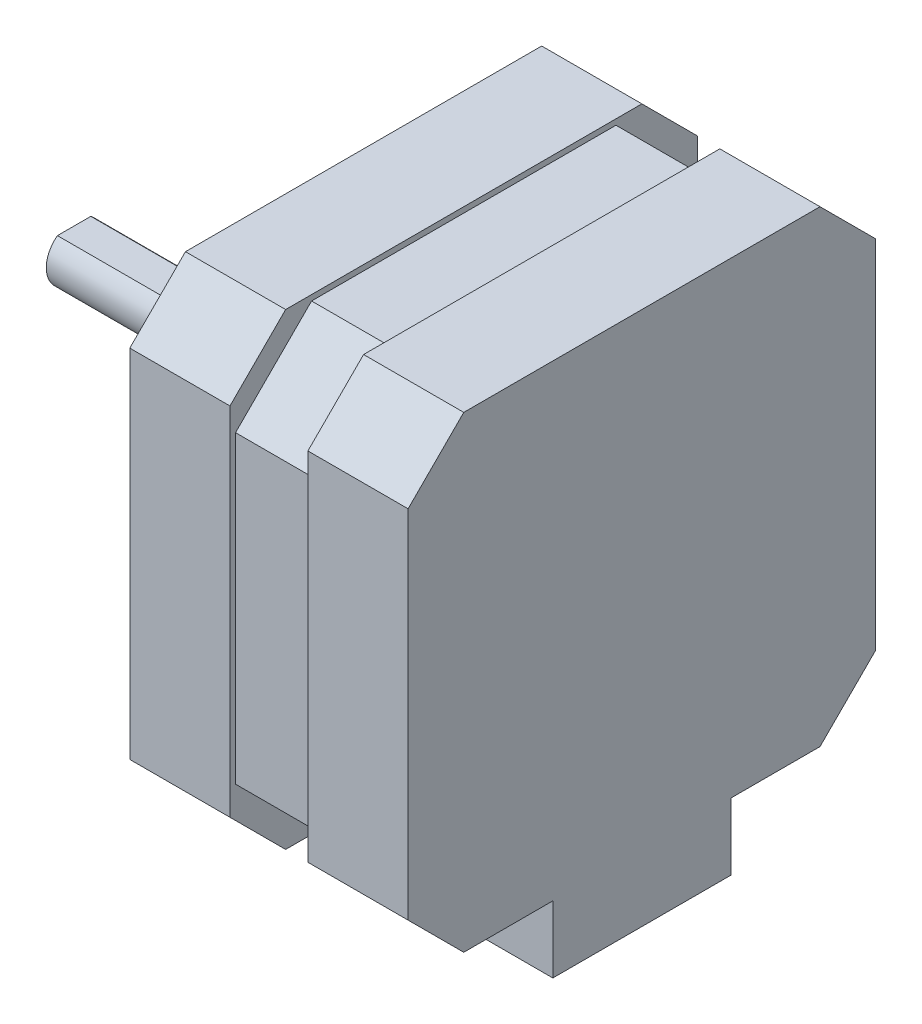
from build123d import *

# Parameters (mm, degrees)
BOSS_EXTRUDE1_DEPTH   = 12.5
CUT_EXTRUDE1_DEPTH    = 3.5
SKETCH4_W             = 7
SKETCH4_H             = 27.34314575
CUT_EXTRUDE2_DEPTH    = 0.5
SKETCH5_W             = 7
SKETCH5_H             = 27.34314575
CUT_EXTRUDE3_DEPTH    = 0.5
SKETCH6_W             = 7
SKETCH6_H             = 27.34314575
CUT_EXTRUDE4_DEPTH    = 0.5
SKETCH7_W             = 7
SKETCH7_H             = 27.34314575
CUT_EXTRUDE5_DEPTH    = 0.5
SKETCH8_R             = 11
BOSS_EXTRUDE2_DEPTH   = 2
SKETCH9_R             = 2.5
BOSS_EXTRUDE3_DEPTH   = 24
M3_TAPPED_HOLE1_D     = 2.5
M3_TAPPED_HOLE1_DEPTH = 6
M3_TAPPED_HOLE1_TIP   = 0.751075774
SKETCH12_W            = 3
SKETCH12_H            = 0.5
CUT_EXTRUDE6_DEPTH    = 20
SKETCH13_W            = 9
SKETCH13_H            = 16
BOSS_EXTRUDE4_DEPTH   = 6


with BuildPart() as part:
    # Sketch1 → Boss-Extrude1 (new body, symmetric)
    with BuildSketch(Plane(origin=(0, 0, 0), x_dir=(0, 0, -1), z_dir=(1, 0, 0))):
        Polygon((-21, 16), (-16, 21), (16, 21), (21, 16), (21, -16), (16, -21), (-16, -21), (-21, -16), align=None)
    extrude(amount=BOSS_EXTRUDE1_DEPTH, both=True)

    # Sketch2 → Cut-Extrude1 (cut, symmetric)
    with BuildSketch(Plane(origin=(0, 0, 0), x_dir=(0, 0, -1), z_dir=(1, 0, 0))):
        Polygon((-21, -13.671572875), (-20.5, -13.671572875), (-13.671572875, -20.5), (-13.671572875, -21), (-16, -21), (-21, -16), align=None)
        Polygon((13.671572875, -21), (13.671572875, -20.5), (20.5, -13.671572875), (21, -13.671572875), (21, -16), (16, -21), align=None)
        Polygon((21, 13.671572875), (20.5, 13.671572875), (13.671572875, 20.5), (13.671572875, 21), (16, 21), (21, 16), align=None)
        Polygon((-13.671572875, 21), (-13.671572875, 20.5), (-20.5, 13.671572875), (-21, 13.671572875), (-21, 16), (-16, 21), align=None)
    extrude(amount=CUT_EXTRUDE1_DEPTH, both=True, mode=Mode.SUBTRACT)

    # Sketch4 → Cut-Extrude2 (cut)
    with BuildSketch(Plane.XY.offset(21)):
        Rectangle(SKETCH4_W, SKETCH4_H)
    extrude(amount=-CUT_EXTRUDE2_DEPTH, mode=Mode.SUBTRACT)

    # Sketch5 → Cut-Extrude3 (cut)
    with BuildSketch(Plane(origin=(0, 21, 0), x_dir=(1, 0, 0), z_dir=(0, 1, 0))):
        Rectangle(SKETCH5_W, SKETCH5_H)
    extrude(amount=-CUT_EXTRUDE3_DEPTH, mode=Mode.SUBTRACT)

    # Sketch6 → Cut-Extrude4 (cut)
    with BuildSketch(Plane(origin=(0, 0, -21), x_dir=(-1, 0, 0), z_dir=(0, 0, -1))):
        Rectangle(SKETCH6_W, SKETCH6_H)
    extrude(amount=-CUT_EXTRUDE4_DEPTH, mode=Mode.SUBTRACT)

    # Sketch7 → Cut-Extrude5 (cut)
    with BuildSketch(Plane.XZ.offset(21)):
        Rectangle(SKETCH7_W, SKETCH7_H)
    extrude(amount=-CUT_EXTRUDE5_DEPTH, mode=Mode.SUBTRACT)

    # Sketch8 → Boss-Extrude2 (add)
    with BuildSketch(Plane.ZY.offset(12.5)):
        Circle(SKETCH8_R)
    extrude(amount=BOSS_EXTRUDE2_DEPTH)

    # Sketch9 → Boss-Extrude3 (add)
    with BuildSketch(Plane.ZY.offset(14.5)):
        Circle(SKETCH9_R)
    extrude(amount=BOSS_EXTRUDE3_DEPTH)

    # M3 Tapped Hole1
    with Locations(Plane.ZY.offset(12.5)):
        with Locations((-15.5, 15.5), (15.5, 15.5), (-15.5, -15.5), (15.5, -15.5)):
            Hole(M3_TAPPED_HOLE1_D / 2, depth=M3_TAPPED_HOLE1_DEPTH)
            with Locations((0, 0, -(M3_TAPPED_HOLE1_DEPTH + M3_TAPPED_HOLE1_TIP / 2))):  # 118° drill point
                Cone(0, M3_TAPPED_HOLE1_D / 2, M3_TAPPED_HOLE1_TIP, mode=Mode.SUBTRACT)

    # Sketch12 → Cut-Extrude6 (cut)
    with BuildSketch(Plane.ZY.offset(38.5)):
        with Locations((0, 2.25)):
            Rectangle(SKETCH12_W, SKETCH12_H)
    extrude(amount=-CUT_EXTRUDE6_DEPTH, mode=Mode.SUBTRACT)

    # Sketch13 → Boss-Extrude4 (add)
    with BuildSketch(Plane.XZ.offset(21)):
        with Locations((8, 0)):
            Rectangle(SKETCH13_W, SKETCH13_H)
    extrude(amount=BOSS_EXTRUDE4_DEPTH)


solid = part.part
